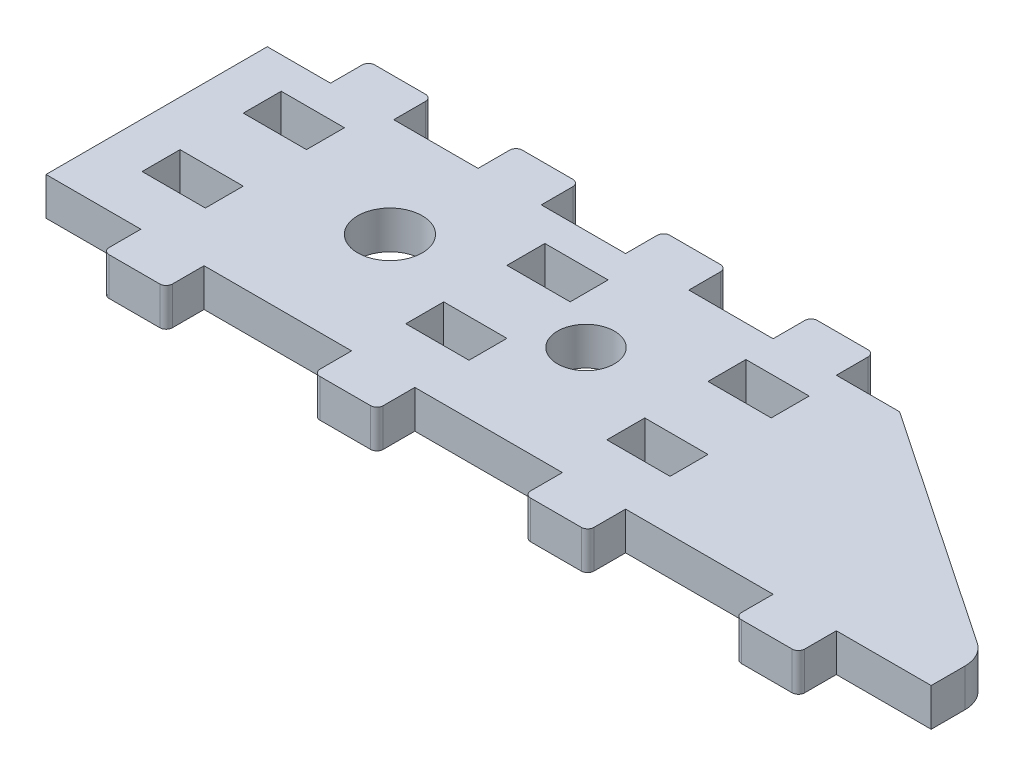
from build123d import *

# Parameters (mm, degrees)
SKETCH1_W              = 140
SKETCH1_H              = 35
BOSS_EXTRUDE1_DEPTH    = 6
SKETCH2_R              = 4.5
SKETCH2_R_2            = 5.1
CUT_EXTRUDE1_DEPTH     = 7
CUT_EXTRUDE2_DEPTH     = 7
SKETCH234_W            = 10
SKETCH234_H            = 6
BOSS_EXTRUDE234_DEPTH  = 6
FILLET134_R            = 1
SKETCH2341_W           = 10
SKETCH2341_H           = 6
BOSS_EXTRUDE2341_DEPTH = 6
FILLET1341_R           = 1
SKETCH2342_W           = 10
SKETCH2342_H           = 6
BOSS_EXTRUDE2342_DEPTH = 6
FILLET1342_R           = 1
SKETCH2343_W           = 10
SKETCH2343_H           = 6
BOSS_EXTRUDE2343_DEPTH = 6
FILLET1343_R           = 1
SKETCH2344_W           = 10
SKETCH2344_H           = 6
BOSS_EXTRUDE2344_DEPTH = 6
FILLET1344_R           = 1
SKETCH2345_W           = 10
SKETCH2345_H           = 6
BOSS_EXTRUDE2345_DEPTH = 6
FILLET1345_R           = 1
SKETCH2346_W           = 10
SKETCH2346_H           = 6
BOSS_EXTRUDE2346_DEPTH = 6
FILLET1346_R           = 1
SKETCH2347_W           = 10
SKETCH2347_H           = 6
BOSS_EXTRUDE2347_DEPTH = 6
FILLET1347_R           = 1
SKETCH6_W              = 10
SKETCH6_H              = 6
CUT_EXTRUDE11_DEPTH    = 4
SKETCH61_W             = 10
SKETCH61_H             = 6
CUT_EXTRUDE12_DEPTH    = 4
SKETCH62_W             = 10
SKETCH62_H             = 6
CUT_EXTRUDE13_DEPTH    = 4
FILLET1348_R           = 5


with BuildPart() as part:
    # Sketch1 → Boss-Extrude1 (new body)
    with BuildSketch(Plane(origin=(0, 0, 0), x_dir=(1, 0, 0), z_dir=(0, 1, 0))):
        with Locations((70, 17.5)):
            Rectangle(SKETCH1_W, SKETCH1_H)
    extrude(amount=BOSS_EXTRUDE1_DEPTH)

    # Sketch2 → Cut-Extrude1 (cut, through all)
    with BuildSketch(Plane(origin=(0, 6, 0), x_dir=(1, 0, 0), z_dir=(0, 1, 0))):
        with Locations((66.4, 19)):
            Circle(SKETCH2_R)
        with Locations((35.4, 19)):
            Circle(SKETCH2_R_2)
    extrude(amount=-CUT_EXTRUDE1_DEPTH, mode=Mode.SUBTRACT)

    # Sketch3 → Cut-Extrude2 (cut, through all)
    with BuildSketch(Plane(origin=(0, 6, 0), x_dir=(1, 0, 0), z_dir=(0, 1, 0))):
        Polygon((140, 8), (100, 35), (140, 35), align=None)
    extrude(amount=-CUT_EXTRUDE2_DEPTH, mode=Mode.SUBTRACT)

    # Sketch234 → Boss-Extrude234 (add)
    with BuildSketch(Plane(origin=(119.232221392, 0, 0), x_dir=(1, 0, 0), z_dir=(0, 0, 1))):
        with Locations((0.767778608, 3)):
            Rectangle(SKETCH234_W, SKETCH234_H)
    extrude(amount=BOSS_EXTRUDE234_DEPTH)

    # Fillet134
    fillet134_edges = [part.edges().sort_by_distance(p)[0] for p in [
        (115, 3, 6),
        (125, 3, 6),
    ]]
    fillet(fillet134_edges, radius=FILLET134_R)

    # Sketch2341 → Boss-Extrude2341 (add)
    with BuildSketch(Plane(origin=(85.898888059, 0, 0), x_dir=(1, 0, 0), z_dir=(0, 0, 1))):
        with Locations((0.767778608, 3)):
            Rectangle(SKETCH2341_W, SKETCH2341_H)
    extrude(amount=BOSS_EXTRUDE2341_DEPTH)

    # Fillet1341
    fillet1341_edges = [part.edges().sort_by_distance(p)[0] for p in [
        (91.666666667, 3, 6),
        (81.666666667, 3, 6),
    ]]
    fillet(fillet1341_edges, radius=FILLET1341_R)

    # Sketch2342 → Boss-Extrude2342 (add)
    with BuildSketch(Plane(origin=(52.565554726, 0, 0), x_dir=(1, 0, 0), z_dir=(0, 0, 1))):
        with Locations((0.767778608, 3)):
            Rectangle(SKETCH2342_W, SKETCH2342_H)
    extrude(amount=BOSS_EXTRUDE2342_DEPTH)

    # Fillet1342
    fillet1342_edges = [part.edges().sort_by_distance(p)[0] for p in [
        (58.333333333, 3, 6),
        (48.333333333, 3, 6),
    ]]
    fillet(fillet1342_edges, radius=FILLET1342_R)

    # Sketch2343 → Boss-Extrude2343 (add)
    with BuildSketch(Plane(origin=(19.232221392, 0, 0), x_dir=(1, 0, 0), z_dir=(0, 0, 1))):
        with Locations((0.767778608, 3)):
            Rectangle(SKETCH2343_W, SKETCH2343_H)
    extrude(amount=BOSS_EXTRUDE2343_DEPTH)

    # Fillet1343
    fillet1343_edges = [part.edges().sort_by_distance(p)[0] for p in [
        (25, 3, 6),
        (15, 3, 6),
    ]]
    fillet(fillet1343_edges, radius=FILLET1343_R)

    # Sketch2344 → Boss-Extrude2344 (add)
    with BuildSketch(Plane(origin=(84.232221392, 6, -35), x_dir=(1, 0, 0), z_dir=(0, 0, -1))):
        with Locations((0.767778608, 3)):
            Rectangle(SKETCH2344_W, SKETCH2344_H)
    extrude(amount=BOSS_EXTRUDE2344_DEPTH)

    # Fillet1344
    fillet1344_edges = [part.edges().sort_by_distance(p)[0] for p in [
        (80, 3, -41),
        (90, 3, -41),
    ]]
    fillet(fillet1344_edges, radius=FILLET1344_R)

    # Sketch2345 → Boss-Extrude2345 (add)
    with BuildSketch(Plane(origin=(60.898888059, 6, -35), x_dir=(1, 0, 0), z_dir=(0, 0, -1))):
        with Locations((0.767778608, 3)):
            Rectangle(SKETCH2345_W, SKETCH2345_H)
    extrude(amount=BOSS_EXTRUDE2345_DEPTH)

    # Fillet1345
    fillet1345_edges = [part.edges().sort_by_distance(p)[0] for p in [
        (66.666666667, 3, -41),
        (56.666666667, 3, -41),
    ]]
    fillet(fillet1345_edges, radius=FILLET1345_R)

    # Sketch2346 → Boss-Extrude2346 (add)
    with BuildSketch(Plane(origin=(37.565554726, 6, -35), x_dir=(1, 0, 0), z_dir=(0, 0, -1))):
        with Locations((0.767778608, 3)):
            Rectangle(SKETCH2346_W, SKETCH2346_H)
    extrude(amount=BOSS_EXTRUDE2346_DEPTH)

    # Fillet1346
    fillet1346_edges = [part.edges().sort_by_distance(p)[0] for p in [
        (43.333333333, 3, -41),
        (33.333333333, 3, -41),
    ]]
    fillet(fillet1346_edges, radius=FILLET1346_R)

    # Sketch2347 → Boss-Extrude2347 (add)
    with BuildSketch(Plane(origin=(14.232221392, 6, -35), x_dir=(1, 0, 0), z_dir=(0, 0, -1))):
        with Locations((0.767778608, 3)):
            Rectangle(SKETCH2347_W, SKETCH2347_H)
    extrude(amount=BOSS_EXTRUDE2347_DEPTH)

    # Fillet1347
    fillet1347_edges = [part.edges().sort_by_distance(p)[0] for p in [
        (20, 3, -41),
        (10, 3, -41),
    ]]
    fillet(fillet1347_edges, radius=FILLET1347_R)

    # Sketch6 → Cut-Extrude11 (cut, symmetric)
    with BuildSketch(Plane(origin=(84.932221392, 3, -55), x_dir=(1, 0, 0), z_dir=(0, 1, 0))):
        with Locations((0.767778608, -44)):
            Rectangle(SKETCH6_W, SKETCH6_H)
    cut_extrude11 = extrude(amount=CUT_EXTRUDE11_DEPTH, both=True, mode=Mode.SUBTRACT)

    # Sketch61 → Cut-Extrude12 (cut, symmetric)
    with BuildSketch(Plane(origin=(53.132221392, 3, -55), x_dir=(1, 0, 0), z_dir=(0, 1, 0))):
        with Locations((0.767778608, -44)):
            Rectangle(SKETCH61_W, SKETCH61_H)
    cut_extrude12 = extrude(amount=CUT_EXTRUDE12_DEPTH, both=True, mode=Mode.SUBTRACT)

    # Sketch62 → Cut-Extrude13 (cut, symmetric)
    with BuildSketch(Plane(origin=(11.432221392, 3, -55), x_dir=(1, 0, 0), z_dir=(0, 1, 0))):
        with Locations((0.767778608, -44)):
            Rectangle(SKETCH62_W, SKETCH62_H)
    cut_extrude13 = extrude(amount=CUT_EXTRUDE13_DEPTH, both=True, mode=Mode.SUBTRACT)

    # Mirror1: Cut-Extrude11, Cut-Extrude12, Cut-Extrude13 across plane
    add(cut_extrude11.mirror(Plane.XY.offset(-19)), mode=Mode.SUBTRACT)
    add(cut_extrude12.mirror(Plane.XY.offset(-19)), mode=Mode.SUBTRACT)
    add(cut_extrude13.mirror(Plane.XY.offset(-19)), mode=Mode.SUBTRACT)

    # Fillet1348
    fillet1348_edges = [part.edges().sort_by_distance(p)[0] for p in [
        (140, 3, -8),
    ]]
    fillet(fillet1348_edges, radius=FILLET1348_R)


solid = part.part
